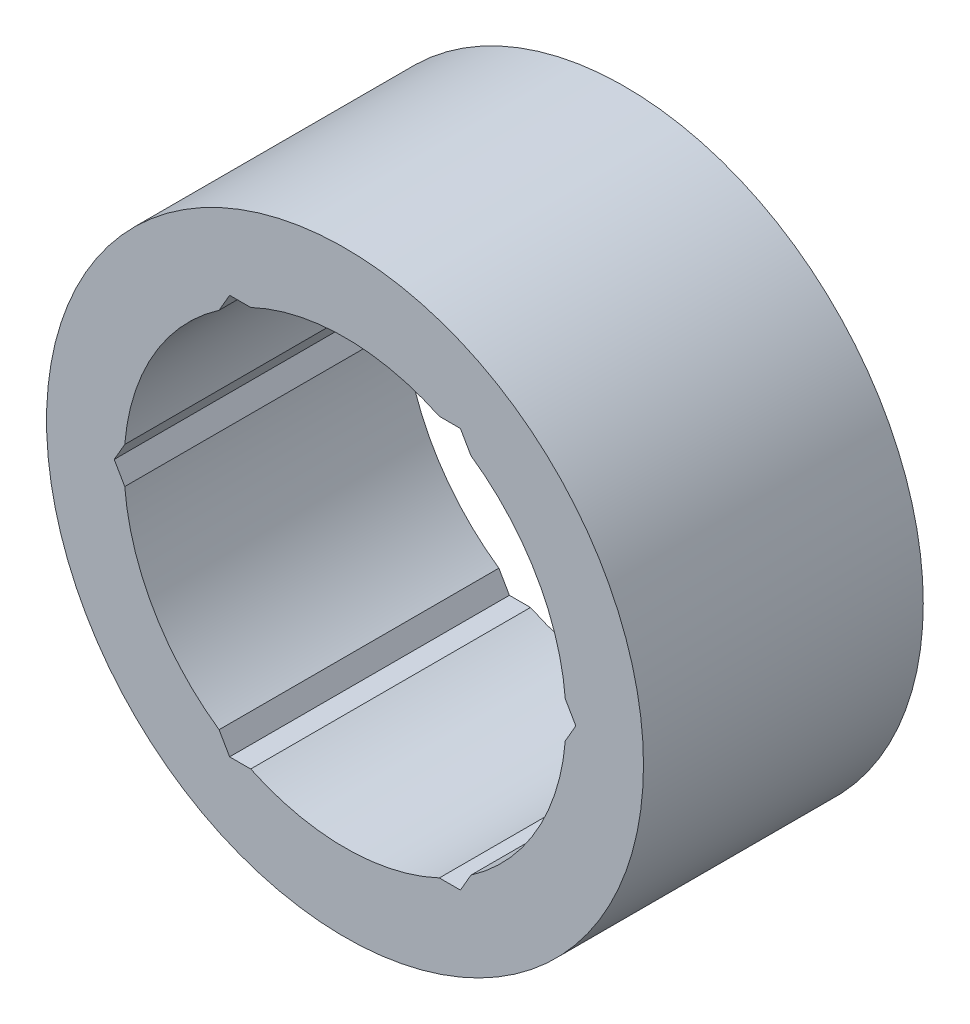
from build123d import *

# Parameters (mm, degrees)
SKETCH1_R           = 10.668
SKETCH1_R_2         = 7.8994
EXTRUDE_THIN1_DEPTH = 5
CUT_EXTRUDE3_DEPTH  = 11


with BuildPart() as part:
    # Sketch1 → Extrude-Thin1 (new body, symmetric)
    with BuildSketch(Plane.XY):
        Circle(SKETCH1_R)
        Circle(SKETCH1_R_2, mode=Mode.SUBTRACT)
    extrude(amount=EXTRUDE_THIN1_DEPTH, both=True)

    # Sketch3 → Cut-Extrude3 (cut, through all)
    with BuildSketch(Plane.XY.offset(5)):
        Polygon((4.124445986, 7.14375), (-4.124445986, 7.14375), (-8.248891971, 0), (-4.124445986, -7.14375), (4.124445986, -7.14375), (8.248891971, 0), align=None)
    extrude(amount=-CUT_EXTRUDE3_DEPTH, mode=Mode.SUBTRACT)


solid = part.part
